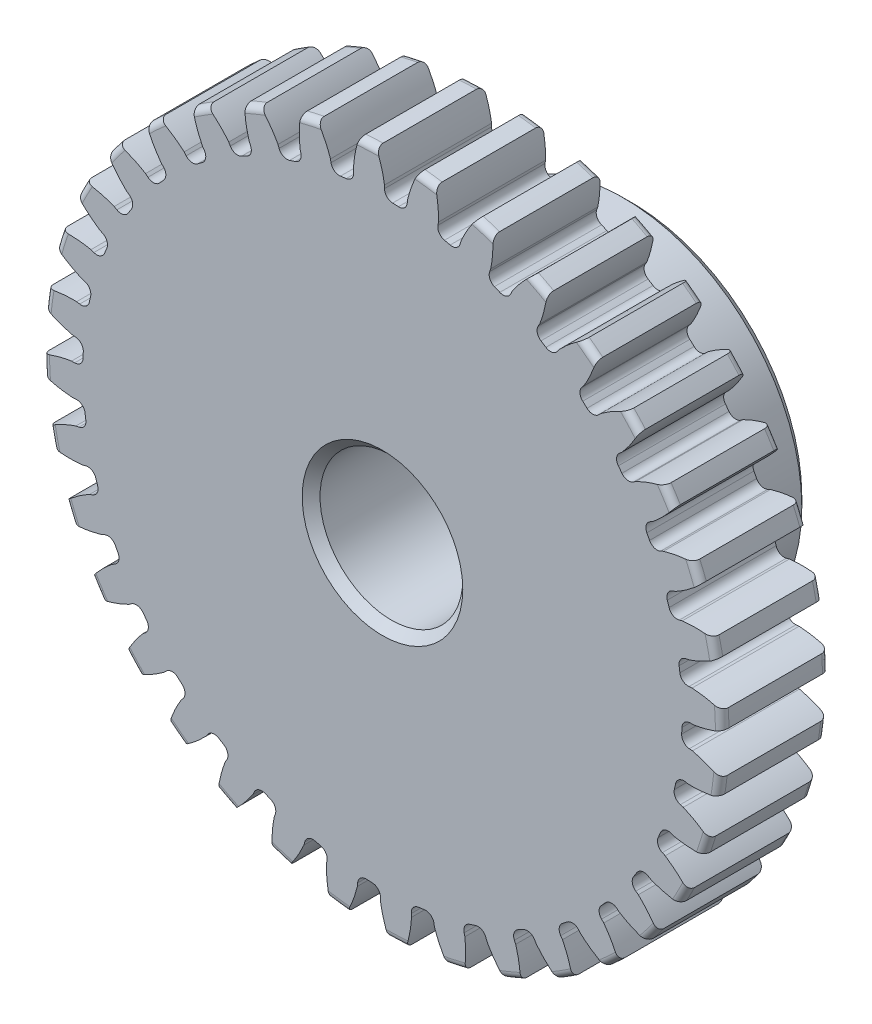
from build123d import *

# Parameters (mm, degrees)
SKETCH1_R                = 15.113
BOSS_EXTRUDE1_DEPTH      = 4.7625
SKETCH2_W                = 6.35
SKETCH2_H                = 7.9375
FILLET2_R                = 0.30226
CUT_EXTRUDE1_DEPTH       = 12.1125
FILLET1_R                = 0.37404675
CIRPATTERN1_COUNT        = 36
FILLET1_OF_CIRPATTERN1_R = 0.37404675
SKETCH5_R                = 3.175
CUT_EXTRUDE2_DEPTH       = 12.1125
CHAMFER1_SIZE            = 0.396875


with BuildPart() as part:
    # Sketch1 → Boss-Extrude1 (new body)
    with BuildSketch(Plane.XY):
        Circle(SKETCH1_R)
    extrude(amount=-BOSS_EXTRUDE1_DEPTH)

    # Sketch2 → Revolve1 (revolve)
    with BuildSketch(Plane(origin=(0, 0, 0), x_dir=(0, 0, -1), z_dir=(1, 0, 0))):
        with Locations((7.9375, 3.96875)):
            Rectangle(SKETCH2_W, SKETCH2_H)
    revolve(axis=Axis((0, 0, -4.7625), (0, 0, -1)))

    # Fillet2
    fillet2_edges = [part.edges().sort_by_distance(p)[0] for p in [
        (-15.113, 0, 0),
        (-15.113, 0, -4.7625),
        (0, -7.9375, -4.7625),
    ]]
    fillet(fillet2_edges, radius=FILLET2_R)

    # Sketch4 → Cut-Extrude1 (cut, through all)
    with BuildSketch(Plane.XY):
        with BuildLine():
            Line((0.089839372, 13.832117662), (0.089839372, 13.326759687))
            ThreePointArc((0.089839372, 13.326759687), (0.58131966, 13.31437803), (1.072008843, 13.283877142))
            Line((1.072008843, 13.283877142), (1.116053796, 13.787312068))
            add(Edge.make_bspline(
                [(2.879412409, 16.608594762), (1.511094277, 15.415219527), (1.116053796, 13.787312068)],
                knots=[0, 0, 0, 1, 1, 1], degree=2))
            ThreePointArc((2.879412409, 16.608594762), (0.73526525, 16.840303465), (-1.420917535, 16.796351662))
            add(Edge.make_bspline(
                [(-1.420917535, 16.796351662), (-0.161816039, 15.48826054), (0.089839372, 13.832117662)],
                knots=[0, 0, 0, 1, 1, 1], degree=2))
        make_face()
    cut_extrude1 = extrude(amount=-CUT_EXTRUDE1_DEPTH, mode=Mode.SUBTRACT)

    # Fillet1
    fillet1_edges = [part.edges().sort_by_distance(p)[0] for p in [
        (1.072008843, 13.283877142, -2.38125),
        (0.089839372, 13.326759687, -2.38125),
    ]]
    fillet(fillet1_edges, radius=FILLET1_R)

    # CirPattern1: Cut-Extrude1 ×36 about axis
    cirpattern1_axis = Axis((0, 0, -4.7625), (0, 0, 1))
    for i in range(1, CIRPATTERN1_COUNT):
        add(cut_extrude1.rotate(cirpattern1_axis, i * 360 / CIRPATTERN1_COUNT), mode=Mode.SUBTRACT)

    # Fillet1 of CirPattern1
    fillet1_of_cirpattern1_edges = [part.edges().sort_by_distance(p)[0] for p in [
        (-1.250998438, 13.268217581, -2.38125),
        (-2.225693024, 13.139896706, -2.38125),
        (-3.535994764, 12.849409944, -2.38125),
        (-4.473598863, 12.553784612, -2.38125),
        (-5.713551679, 12.040179487, -2.38125),
        (-6.585576665, 11.586232126, -2.38125),
        (-7.717505218, 10.86511427, -2.38125),
        (-8.497455052, 10.266637839, -2.38125),
        (-9.486966266, 9.359918053, -2.38125),
        (-10.151142568, 8.635096956, -2.38125),
        (-10.968170644, 7.570325462, -2.38125),
        (-11.496392753, 6.741183022, -2.38125),
        (-12.116112707, 5.550712364, -2.38125),
        (-12.492330862, 4.642441654, -2.38125),
        (-12.895912817, 3.362443678, -2.38125),
        (-13.108695819, 2.402642044, -2.38125),
        (-13.283877142, 1.072008843, -2.38125),
        (-13.326759687, 0.089839372, -2.38125),
        (-13.268217581, -1.250998438, -2.38125),
        (-13.139896706, -2.225693024, -2.38125),
        (-12.849409944, -3.535994764, -2.38125),
        (-12.553784612, -4.473598863, -2.38125),
        (-12.040179487, -5.713551679, -2.38125),
        (-11.586232126, -6.585576665, -2.38125),
        (-10.86511427, -7.717505218, -2.38125),
        (-10.266637839, -8.497455052, -2.38125),
        (-9.359918053, -9.486966266, -2.38125),
        (-8.635096956, -10.151142568, -2.38125),
        (-7.570325462, -10.968170644, -2.38125),
        (-6.741183022, -11.496392753, -2.38125),
        (-5.550712364, -12.116112707, -2.38125),
        (-4.642441654, -12.492330862, -2.38125),
        (-3.362443678, -12.895912817, -2.38125),
        (-2.402642044, -13.108695819, -2.38125),
        (-1.072008843, -13.283877142, -2.38125),
        (-0.089839372, -13.326759687, -2.38125),
        (1.250998438, -13.268217581, -2.38125),
        (2.225693024, -13.139896706, -2.38125),
        (3.535994764, -12.849409944, -2.38125),
        (4.473598863, -12.553784612, -2.38125),
        (5.713551679, -12.040179487, -2.38125),
        (6.585576665, -11.586232126, -2.38125),
        (7.717505218, -10.86511427, -2.38125),
        (8.497455052, -10.266637839, -2.38125),
        (9.486966266, -9.359918053, -2.38125),
        (10.151142568, -8.635096956, -2.38125),
        (10.968170644, -7.570325462, -2.38125),
        (11.496392753, -6.741183022, -2.38125),
        (12.116112707, -5.550712364, -2.38125),
        (12.492330862, -4.642441654, -2.38125),
        (12.895912817, -3.362443678, -2.38125),
        (13.108695819, -2.402642044, -2.38125),
        (13.283877142, -1.072008843, -2.38125),
        (13.326759687, -0.089839372, -2.38125),
        (13.268217581, 1.250998438, -2.38125),
        (13.139896706, 2.225693024, -2.38125),
        (12.849409944, 3.535994764, -2.38125),
        (12.553784612, 4.473598863, -2.38125),
        (12.040179487, 5.713551679, -2.38125),
        (11.586232126, 6.585576665, -2.38125),
        (10.86511427, 7.717505218, -2.38125),
        (10.266637839, 8.497455052, -2.38125),
        (9.359918053, 9.486966266, -2.38125),
        (8.635096956, 10.151142568, -2.38125),
        (7.570325462, 10.968170644, -2.38125),
        (6.741183022, 11.496392753, -2.38125),
        (5.550712364, 12.116112707, -2.38125),
        (4.642441654, 12.492330862, -2.38125),
        (3.362443678, 12.895912817, -2.38125),
        (2.402642044, 13.108695819, -2.38125),
    ]]
    fillet(fillet1_of_cirpattern1_edges, radius=FILLET1_OF_CIRPATTERN1_R)

    # Sketch5 → Cut-Extrude2 (cut, through all)
    with BuildSketch(Plane.XY):
        Circle(SKETCH5_R)
    extrude(amount=-CUT_EXTRUDE2_DEPTH, mode=Mode.SUBTRACT)

    # Chamfer1
    chamfer1_edges = [part.edges().sort_by_distance(p)[0] for p in [
        (-3.175, 0, -11.1125),
        (-3.175, 0, 0),
        (0, -7.9375, -11.1125),
    ]]
    chamfer(chamfer1_edges, length=CHAMFER1_SIZE)


solid = part.part
